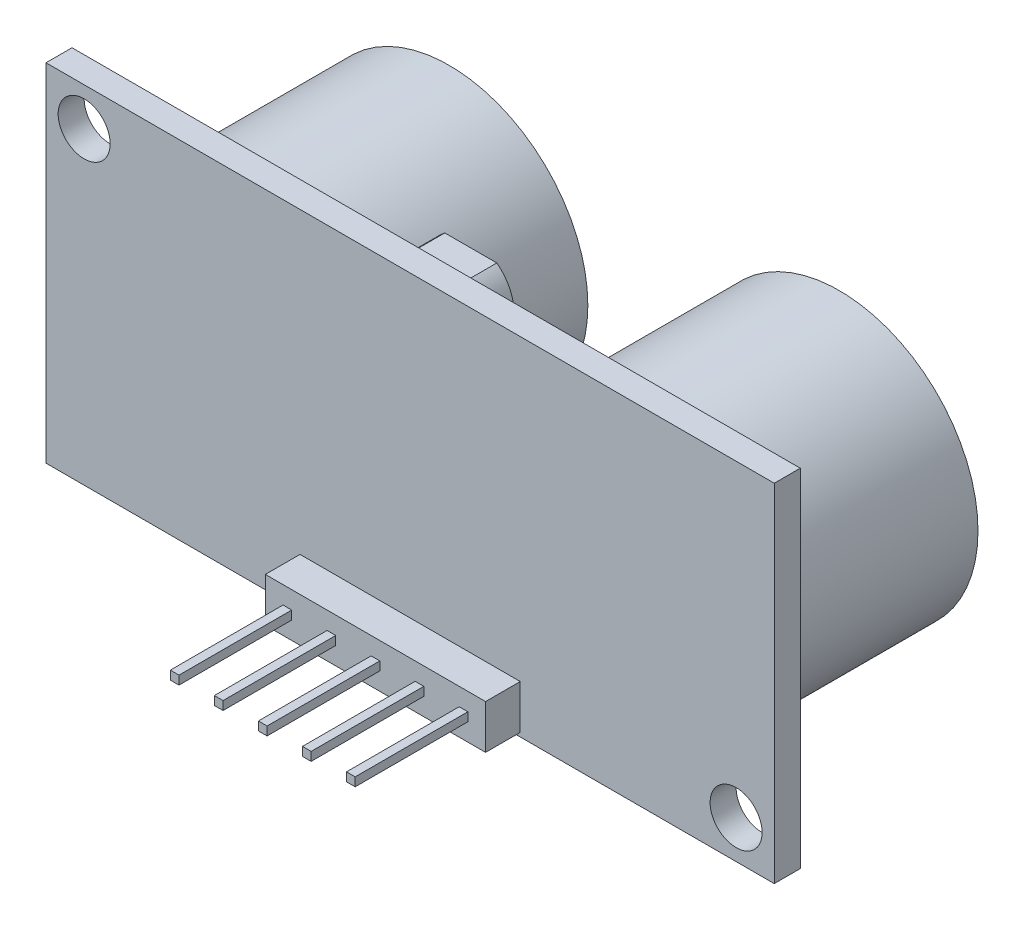
from build123d import *

# Parameters (mm, degrees)
CROQUIS1_W                   = 42
CROQUIS1_H                   = 20
CROQUIS1_R                   = 1.5
SALIENTE_EXTRUIR1_DEPTH      = 1.5
CROQUIS2_R                   = 8
SALIENTE_EXTRUIR2_DEPTH      = 12
CROQUIS3_R                   = 6.5
CORTAR_EXTRUIR1_DEPTH        = 0.5
CROQUIS5_W                   = 0.5
CROQUIS5_H                   = 0.5
SALIENTE_EXTRUIR3_DEPTH      = 8.5
SALIENTE_EXTRUIR3_DEPTH_BACK = 3
CROQUIS6_W                   = 12.7
CROQUIS6_H                   = 2.54
SALIENTE_EXTRUIR4_DEPTH      = 2
SALIENTE_EXTRUIR5_DEPTH      = 4
SALIENTE_EXTRUIR6_DEPTH      = 2


with BuildPart() as part:
    # Croquis1 → Saliente-Extruir1 (new body)
    with BuildSketch(Plane.XY):
        Rectangle(CROQUIS1_W, CROQUIS1_H)
        with Locations((-18.8, 7.8)):
            Circle(CROQUIS1_R, mode=Mode.SUBTRACT)
        with Locations((18.8, -7.8)):
            Circle(CROQUIS1_R, mode=Mode.SUBTRACT)
    extrude(amount=-SALIENTE_EXTRUIR1_DEPTH)

    # Croquis2 → Saliente-Extruir2 (add)
    with BuildSketch(Plane(origin=(0, 0, -1.5), x_dir=(-1, 0, 0), z_dir=(0, 0, -1))):
        with Locations((-11.25, 0)):
            Circle(CROQUIS2_R)
        with Locations((11.25, 0)):
            Circle(CROQUIS2_R)
    extrude(amount=SALIENTE_EXTRUIR2_DEPTH)

    # Croquis3 → Cortar-Extruir1 (cut)
    with BuildSketch(Plane(origin=(0, 0, -13.5), x_dir=(-1, 0, 0), z_dir=(0, 0, -1))):
        with Locations((-11.25, 0)):
            Circle(CROQUIS3_R)
        with Locations((11.25, 0)):
            Circle(CROQUIS3_R)
    extrude(amount=-CORTAR_EXTRUIR1_DEPTH, mode=Mode.SUBTRACT)

    # Croquis5 → Saliente-Extruir3 (add, two sides)
    with BuildSketch(Plane.XY) as saliente_extruir3_sk:
        with Locations((0, -8.5)):
            Rectangle(CROQUIS5_W, CROQUIS5_H)
        with Locations((-2.54, -8.5)):
            Rectangle(CROQUIS5_W, CROQUIS5_H)
        with Locations((-5.08, -8.5)):
            Rectangle(CROQUIS5_W, CROQUIS5_H)
        with Locations((2.54, -8.5)):
            Rectangle(CROQUIS5_W, CROQUIS5_H)
        with Locations((5.08, -8.5)):
            Rectangle(CROQUIS5_W, CROQUIS5_H)
    extrude(amount=SALIENTE_EXTRUIR3_DEPTH)
    extrude(saliente_extruir3_sk.sketch, amount=-SALIENTE_EXTRUIR3_DEPTH_BACK)

    # Croquis6 → Saliente-Extruir4 (add)
    with BuildSketch(Plane.XY):
        with Locations((0, -8.5)):
            Rectangle(CROQUIS6_W, CROQUIS6_H)
    extrude(amount=SALIENTE_EXTRUIR4_DEPTH)

    # Croquis7 → Saliente-Extruir5 (add)
    with BuildSketch(Plane(origin=(0, 0, -1.5), x_dir=(-1, 0, 0), z_dir=(0, 0, -1))):
        with BuildLine():
            Line((-2.5, -7), (0, -7))
            Line((0, -7), (2.5, -7))
            ThreePointArc((2.5, -7), (0, -4.5), (-2.5, -7))
        make_face()
    extrude(amount=SALIENTE_EXTRUIR5_DEPTH)

    # Croquis8 → Saliente-Extruir6 (add)
    with BuildSketch(Plane(origin=(0, 0, -1.5), x_dir=(-1, 0, 0), z_dir=(0, 0, -1))):
        with BuildLine():
            Line((-1.5, 9.5), (1.5, 9.5))
            ThreePointArc((1.5, 9.5), (2.5, 7.5), (1.5, 5.5))
            Line((1.5, 5.5), (-1.5, 5.5))
            ThreePointArc((-1.5, 5.5), (-2.5, 7.5), (-1.5, 9.5))
        make_face()
    extrude(amount=SALIENTE_EXTRUIR6_DEPTH)


solid = part.part
